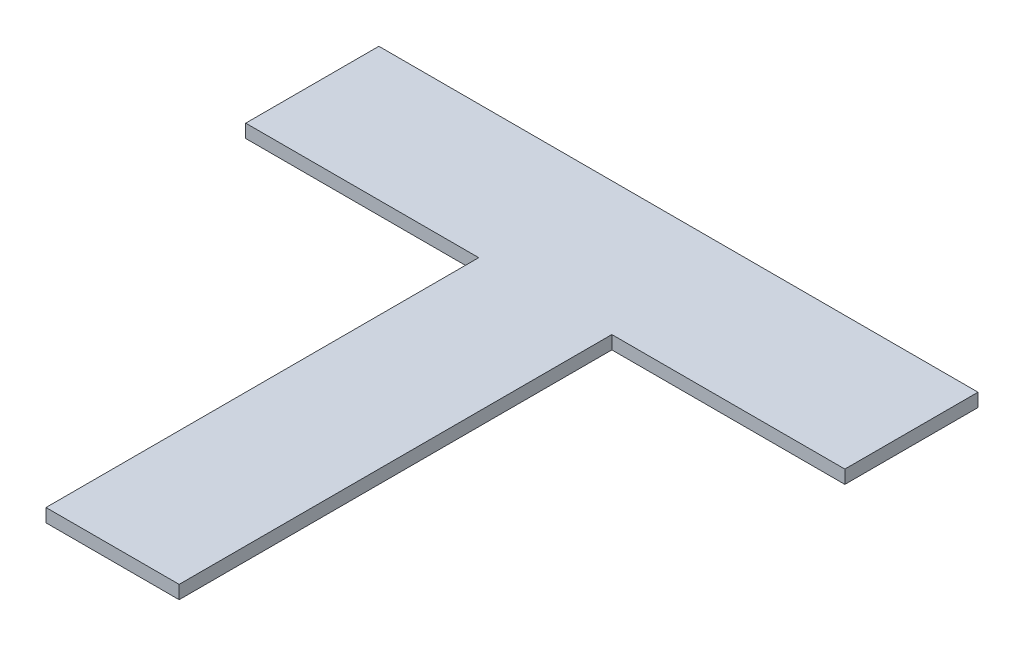
from build123d import *

# Parameters (mm, degrees)
ESQUISSE1_W        = 20
ESQUISSE1_H        = 65
BOSS_EXTRU_1_DEPTH = 2
ESQUISSE2_W        = 90
ESQUISSE2_H        = 2
BOSS_EXTRU_2_DEPTH = 20


with BuildPart() as part:
    # Esquisse1 → Boss.-Extru.1 (new body)
    with BuildSketch(Plane(origin=(0, 0, 0), x_dir=(1, 0, 0), z_dir=(0, 1, 0))):
        with Locations((0, -10)):
            Rectangle(ESQUISSE1_W, ESQUISSE1_H)
    extrude(amount=BOSS_EXTRU_1_DEPTH)

    # Esquisse2 → Boss.-Extru.2 (add)
    with BuildSketch(Plane(origin=(0, 0, -22.5), x_dir=(-1, 0, 0), z_dir=(0, 0, -1))):
        with Locations((0, 1)):
            Rectangle(ESQUISSE2_W, ESQUISSE2_H)
    extrude(amount=BOSS_EXTRU_2_DEPTH)


solid = part.part
